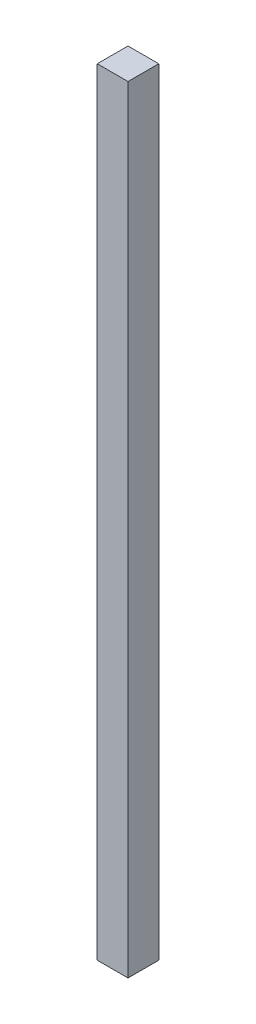
from build123d import *

# Parameters (mm, degrees)
SKETCH2_W           = 76.2
SKETCH2_H           = 76.2
BOSS_EXTRUDE1_DEPTH = 1923.8


with BuildPart() as part:
    # Sketch2 → Boss-Extrude1 (new body)
    with BuildSketch(Plane(origin=(0, 0, 0), x_dir=(1, 0, 0), z_dir=(0, 1, 0))):
        Rectangle(SKETCH2_W, SKETCH2_H)
    extrude(amount=BOSS_EXTRUDE1_DEPTH)


solid = part.part
